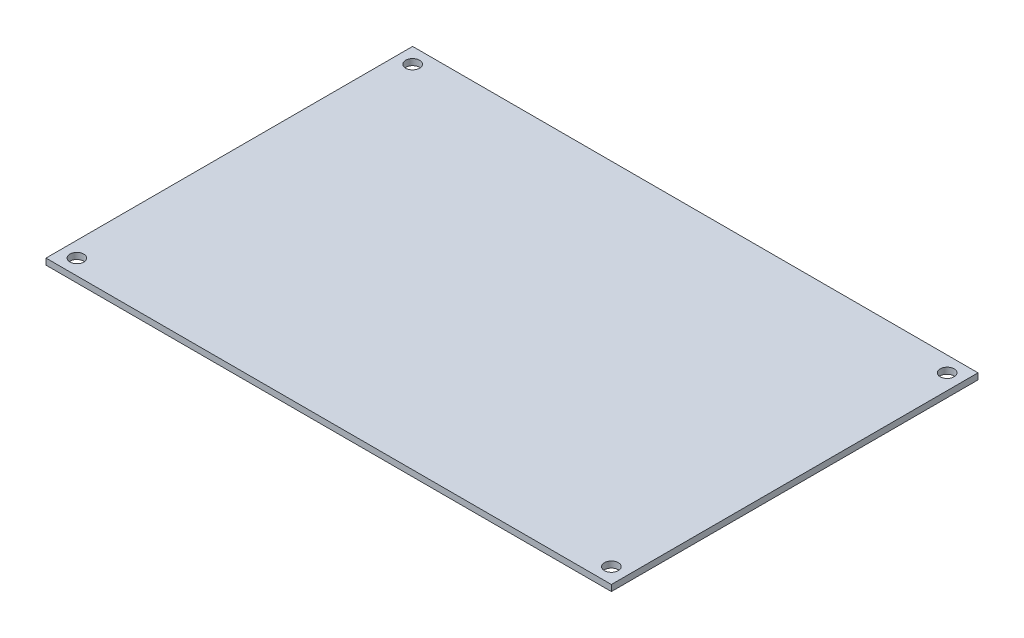
from build123d import *

# Parameters (mm, degrees)
SKETCH2_W           = 146.5
SKETCH2_H           = 95
SKETCH2_R           = 1.8
BOSS_EXTRUDE1_DEPTH = 1.6


with BuildPart() as part:
    # Sketch2 → Boss-Extrude1 (new body)
    with BuildSketch(Plane(origin=(0, 0, 0), x_dir=(1, 0, 0), z_dir=(0, 1, 0))):
        Rectangle(SKETCH2_W, SKETCH2_H)
        with Locations((-69.25, 43.5)):
            Circle(SKETCH2_R, mode=Mode.SUBTRACT)
        with Locations((69.25, 43.5)):
            Circle(SKETCH2_R, mode=Mode.SUBTRACT)
        with Locations((69.25, -43.5)):
            Circle(SKETCH2_R, mode=Mode.SUBTRACT)
        with Locations((-69.25, -43.5)):
            Circle(SKETCH2_R, mode=Mode.SUBTRACT)
    extrude(amount=-BOSS_EXTRUDE1_DEPTH)


solid = part.part
